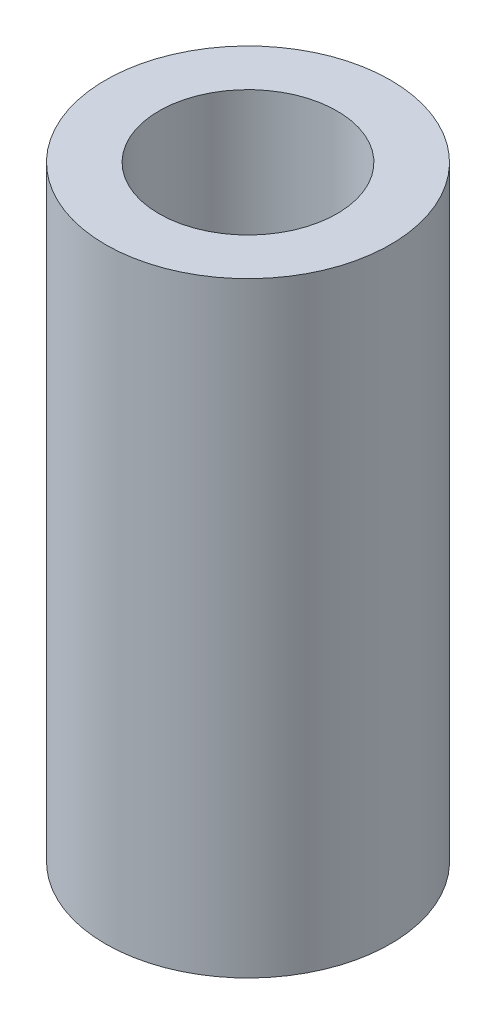
from build123d import *

# Parameters (mm, degrees)
SKETCH2_R           = 4
SKETCH2_R_2         = 2.5
BOSS_EXTRUDE1_DEPTH = 17


with BuildPart() as part:
    # Sketch2 → Boss-Extrude1 (new body)
    with BuildSketch(Plane(origin=(0, 0, 0), x_dir=(1, 0, 0), z_dir=(0, 1, 0))):
        Circle(SKETCH2_R)
        Circle(SKETCH2_R_2, mode=Mode.SUBTRACT)
    extrude(amount=BOSS_EXTRUDE1_DEPTH)


solid = part.part
